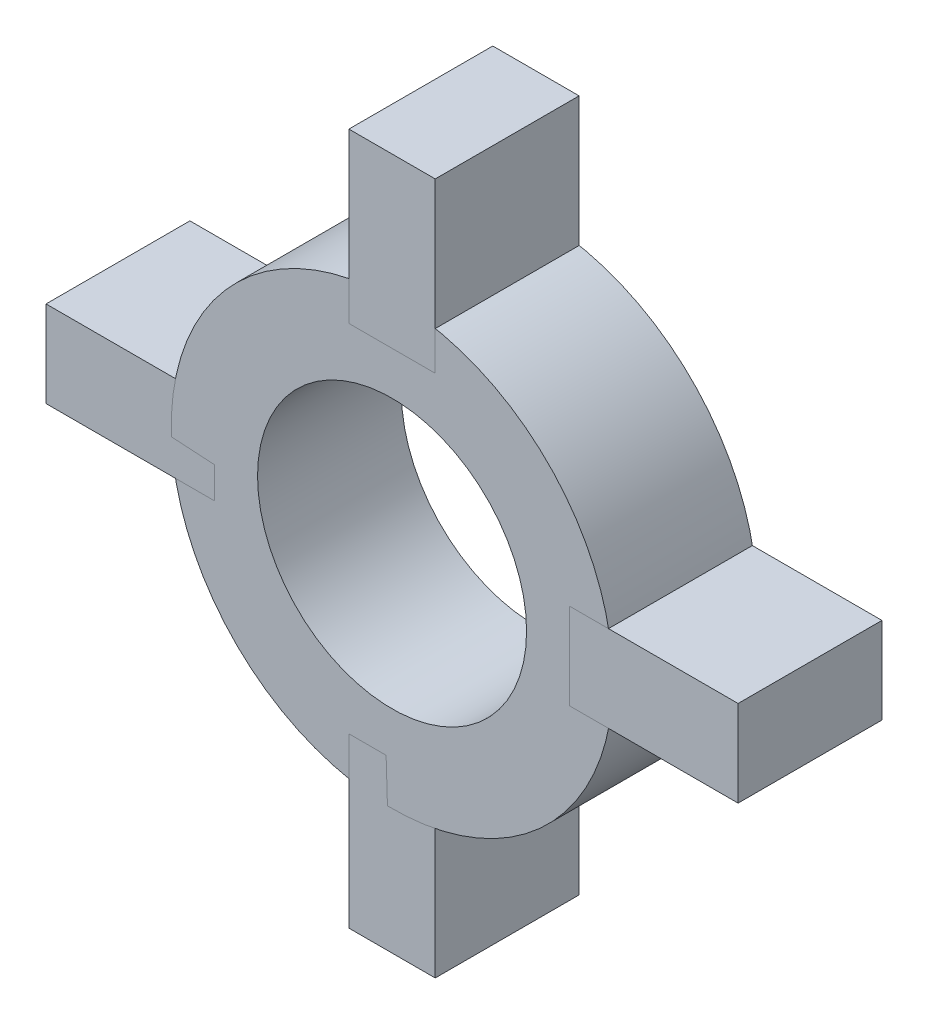
from build123d import *

# Parameters (mm, degrees)
SKETCH1_R             = 7.675
SKETCH1_R_2           = 4.675
EXTRUDE_THIN1_DEPTH   = 5
SKETCH1_W             = 3
SKETCH1_H             = 5.85
EXTRUDE_THIN1_2_DEPTH = 5
EXTRUDE_THIN1_3_DEPTH = 5
SKETCH1_W_2           = 5.85
SKETCH1_H_2           = 3
EXTRUDE_THIN1_4_DEPTH = 5
EXTRUDE_THIN1_5_DEPTH = 5


with BuildPart() as part:
    # Sketch1 → Extrude-Thin1 (new body)
    with BuildSketch(Plane.XY):
        Circle(SKETCH1_R)
        Circle(SKETCH1_R_2, mode=Mode.SUBTRACT)
    extrude(amount=EXTRUDE_THIN1_DEPTH)


with BuildPart() as body_2:
    # Sketch1 → Extrude-Thin1 2 (new body)
    with BuildSketch(Plane.XY):
        with Locations((0, 9.1)):
            Rectangle(SKETCH1_W, SKETCH1_H)
    extrude(amount=EXTRUDE_THIN1_2_DEPTH)


with BuildPart() as body_3:
    # Sketch1 → Extrude-Thin1 3 (new body)
    with BuildSketch(Plane.XY):
        with Locations((0, -9.1)):
            Rectangle(SKETCH1_W, SKETCH1_H)
    extrude(amount=EXTRUDE_THIN1_3_DEPTH)


with BuildPart() as body_4:
    # Sketch1 → Extrude-Thin1 4 (new body)
    with BuildSketch(Plane.XY):
        with Locations((9.1, 0)):
            Rectangle(SKETCH1_W_2, SKETCH1_H_2)
    extrude(amount=EXTRUDE_THIN1_4_DEPTH)


with BuildPart() as body_5:
    # Sketch1 → Extrude-Thin1 5 (new body)
    with BuildSketch(Plane.XY):
        with Locations((-9.1, 0)):
            Rectangle(SKETCH1_W_2, SKETCH1_H_2)
    extrude(amount=EXTRUDE_THIN1_5_DEPTH)


solid = Compound([part.part, body_2.part, body_3.part, body_4.part, body_5.part])
